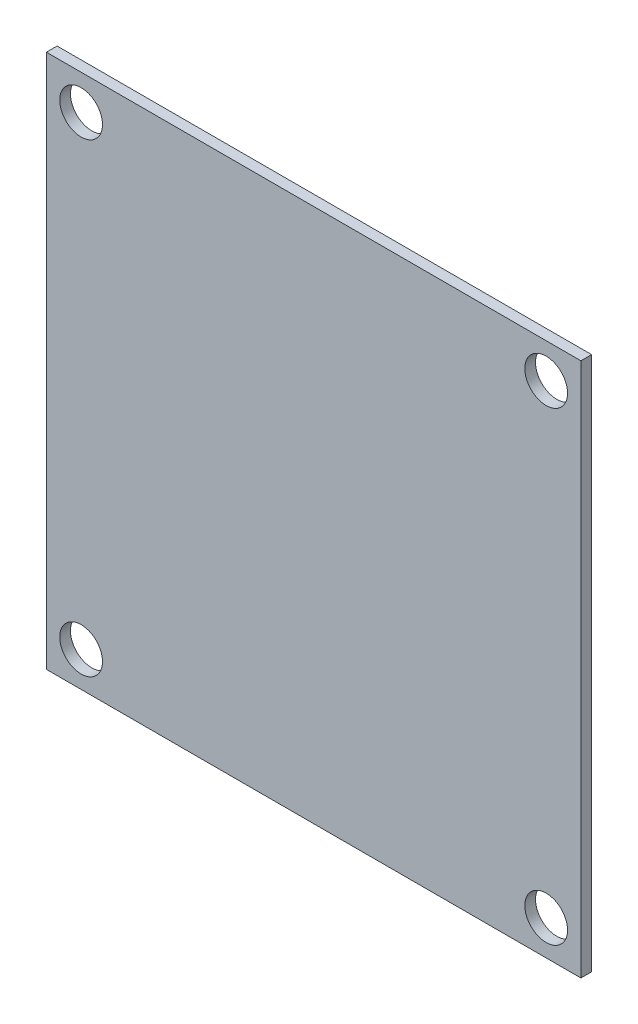
from build123d import *

# Parameters (mm, degrees)
SKETCH1_W           = 40
SKETCH1_H           = 40
BOSS_EXTRUDE1_DEPTH = 0.8
SKETCH2_R           = 1.6
CUT_EXTRUDE1_DEPTH  = 0.8


with BuildPart() as part:
    # Sketch1 → Boss-Extrude1 (new body)
    with BuildSketch(Plane.XY):
        Rectangle(SKETCH1_W, SKETCH1_H)
    extrude(amount=BOSS_EXTRUDE1_DEPTH)

    # Sketch2 → Cut-Extrude1 (cut)
    with BuildSketch(Plane.XY):
        with Locations((-17.4, -17.4)):
            Circle(SKETCH2_R)
        with Locations((-17.4, 17.4)):
            Circle(SKETCH2_R)
        with Locations((17.4, 17.4)):
            Circle(SKETCH2_R)
        with Locations((17.4, -17.4)):
            Circle(SKETCH2_R)
    extrude(amount=CUT_EXTRUDE1_DEPTH, mode=Mode.SUBTRACT)


solid = part.part
